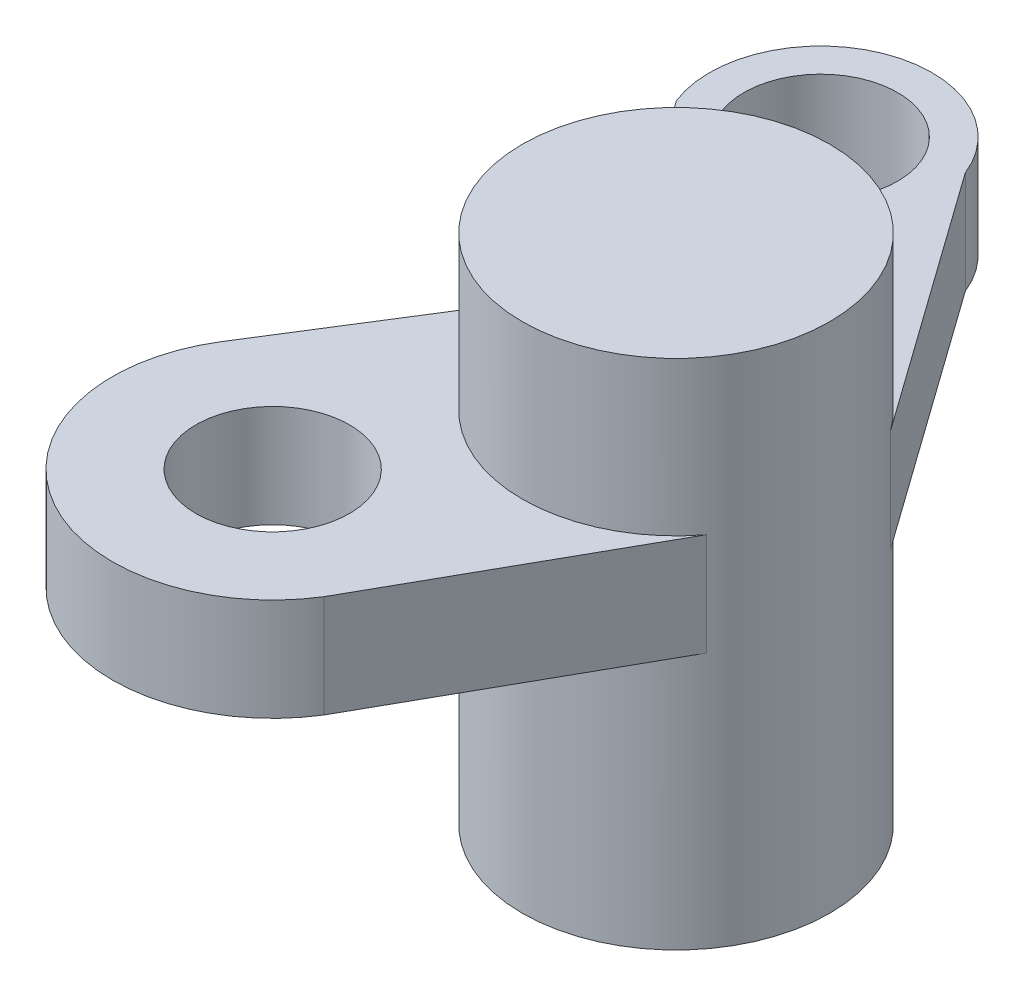
from build123d import *

# Parameters (mm, degrees)
BOSS_EXTRUDE1_DEPTH = 10
BOSS_EXTRUDE2_START = 5
SKETCH1_3_R         = 1.5
BOSS_EXTRUDE2_DEPTH = 2


with BuildPart() as part:
    # Sketch1 → Boss-Extrude1 (new body)
    with BuildSketch(Plane(origin=(0, 0, 0), x_dir=(1, 0, 0), z_dir=(0, 1, 0))):
        with BuildLine():
            ThreePointArc((-2.557799528, 3.74231365), (-5.08812745, 4.998705313), (-7.54030513, 3.595885286))
            ThreePointArc((-7.54030513, 3.595885286), (-6.702483219, -0.470131755), (-2.604511851, 0.193999854))
            ThreePointArc((-2.604511851, 0.193999854), (-2.155139331, 1.047756451), (-2, 2))
            ThreePointArc((-2, 2), (-2.142850947, 2.914712683), (-2.557799528, 3.74231365))
        make_face()
    extrude(amount=BOSS_EXTRUDE1_DEPTH)

    # Sketch1_3 → Boss-Extrude2 (add)
    # profile 1 of 2: a face of its own
    with BuildSketch(Plane(origin=(0, 0, 0), x_dir=(1, 0, 0), z_dir=(0, 1, 0)).offset(BOSS_EXTRUDE2_START)):
        with BuildLine():
            ThreePointArc((-2.604511851, 0.193999854), (-6.702483219, -0.470131755), (-7.54030513, 3.595885286))
            Line((-7.54030513, 3.595885286), (-10.599067222, -1.273004164))
            ThreePointArc((-10.599067222, -1.273004164), (-9.599794928, -5.584355236), (-5.288443855, -4.585082942))
            Line((-5.288443855, -4.585082942), (-2.604511851, 0.193999854))
        make_face()
        with Locations((-7.943755539, -2.929043553)):
            Circle(SKETCH1_3_R, mode=Mode.SUBTRACT)
    # profile 2 of 2: a face of its own
    with BuildSketch(Plane(origin=(0, 0, 0), x_dir=(1, 0, 0), z_dir=(0, 1, 0)).offset(BOSS_EXTRUDE2_START)):
        with BuildLine():
            Line((-10.230926638, 7.234880355), (-7.54030513, 3.595885286))
            ThreePointArc((-7.54030513, 3.595885286), (-5.08812745, 4.998705313), (-2.557799528, 3.74231365))
            Line((-2.557799528, 3.74231365), (-6.192479387, 8.837043218))
            ThreePointArc((-6.192479387, 8.837043218), (-9.012784444, 10.055185412), (-10.230926638, 7.234880355))
        make_face()
        with Locations((-8.211703012, 8.035961786)):
            Circle(SKETCH1_3_R, mode=Mode.SUBTRACT)
    extrude(amount=BOSS_EXTRUDE2_DEPTH)


solid = part.part
